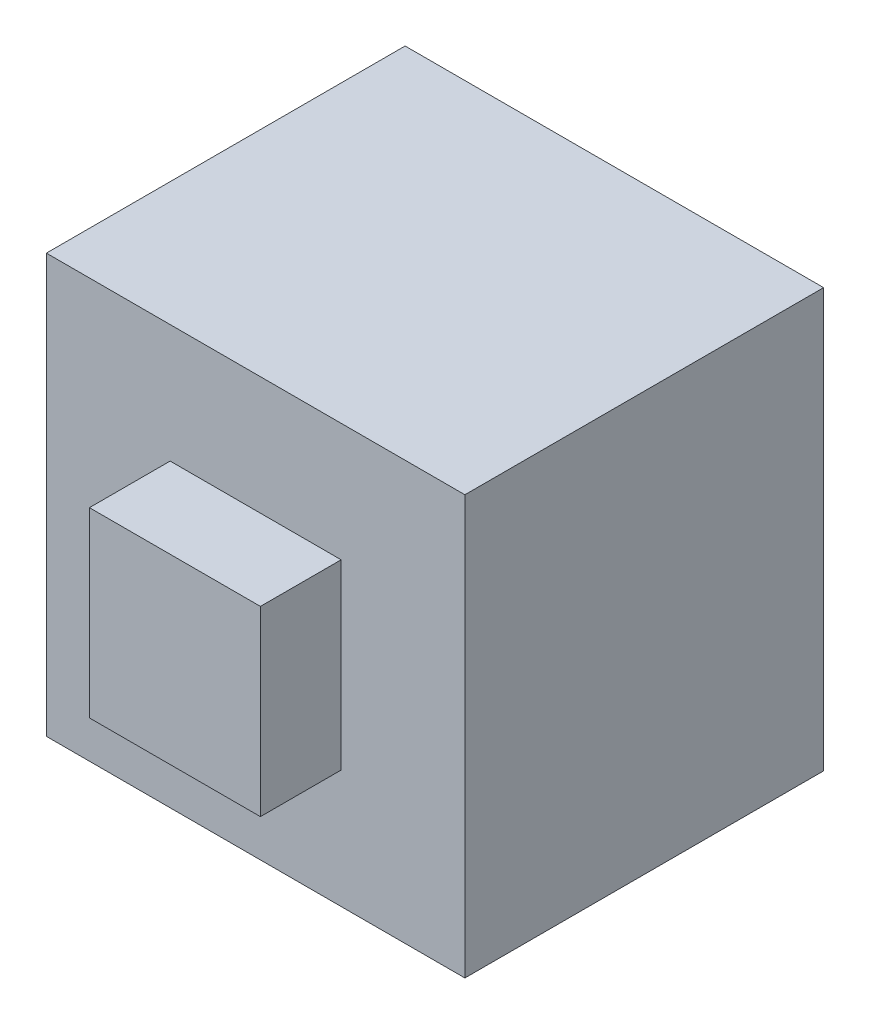
from build123d import *

# Parameters (mm, degrees)
SKETCH2_W           = 140
SKETCH2_H           = 140
BOSS_EXTRUDE1_DEPTH = 120
SKETCH3_W           = 57.199115384
SKETCH3_H           = 60.913343656
BOSS_EXTRUDE2_DEPTH = 27


with BuildPart() as part:
    # Sketch2 → Boss-Extrude1 (new body)
    with BuildSketch(Plane.XY):
        Rectangle(SKETCH2_W, SKETCH2_H)
    extrude(amount=BOSS_EXTRUDE1_DEPTH)

    # Sketch3 → Boss-Extrude2 (add)
    with BuildSketch(Plane.XY.offset(120)):
        Rectangle(SKETCH3_W, SKETCH3_H)
    extrude(amount=BOSS_EXTRUDE2_DEPTH)


solid = part.part
